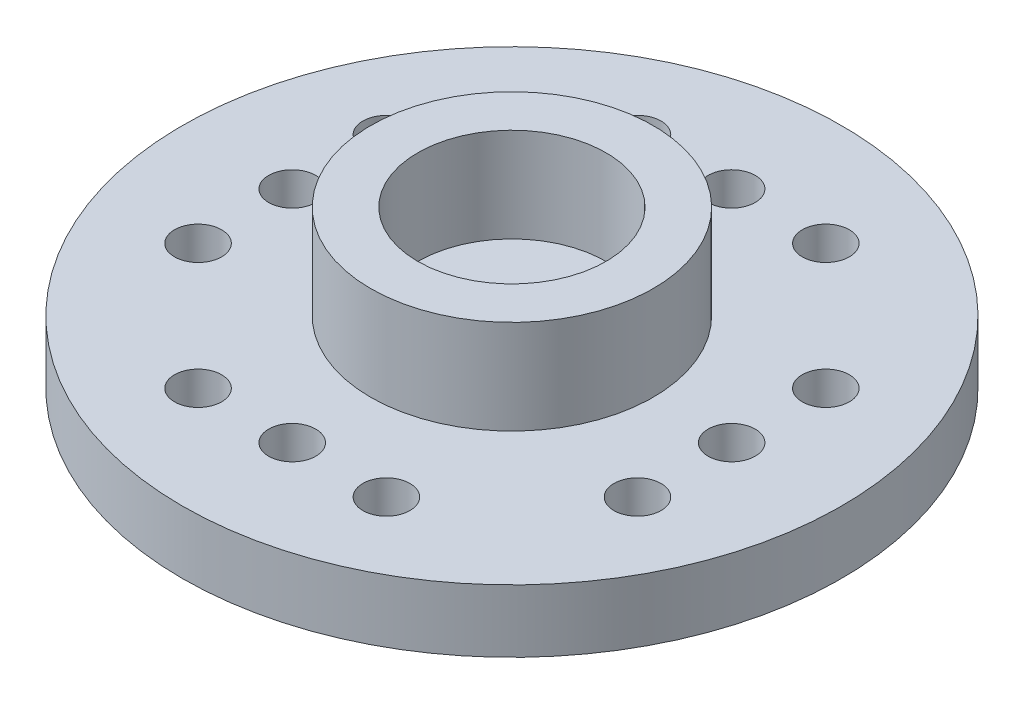
from build123d import *

# Parameters (mm, degrees)
SKETCH1_R           = 10.5
BOSS_EXTRUDE1_DEPTH = 2
SKETCH2_R           = 4.5
SKETCH2_R_2         = 3
BOSS_EXTRUDE2_DEPTH = 3
SKETCH3_R           = 1
CUT_EXTRUDE1_DEPTH  = 3
SKETCH4_R           = 4.25
SKETCH4_R_2         = 3.25
SKETCH4_R_3         = 2.75
SKETCH4_R_4         = 1
CUT_EXTRUDE2_DEPTH  = 0.5
SKETCH5_R           = 0.75
CUT_EXTRUDE3_DEPTH  = 2.5
SKETCH7_R           = 0.75
CUT_EXTRUDE4_DEPTH  = 2.5


with BuildPart() as part:
    # Sketch1 → Boss-Extrude1 (new body)
    with BuildSketch(Plane(origin=(0, 0, 0), x_dir=(1, 0, 0), z_dir=(0, 1, 0))):
        Circle(SKETCH1_R)
    extrude(amount=BOSS_EXTRUDE1_DEPTH)

    # Sketch2 → Boss-Extrude2 (add)
    with BuildSketch(Plane(origin=(0, 2, 0), x_dir=(1, 0, 0), z_dir=(0, 1, 0))):
        Circle(SKETCH2_R)
        Circle(SKETCH2_R_2, mode=Mode.SUBTRACT)
    extrude(amount=BOSS_EXTRUDE2_DEPTH)

    # Sketch3 → Cut-Extrude1 (cut)
    with BuildSketch(Plane(origin=(0, 2, 0), x_dir=(1, 0, 0), z_dir=(0, 1, 0))):
        Circle(SKETCH3_R)
    extrude(amount=-CUT_EXTRUDE1_DEPTH, mode=Mode.SUBTRACT)

    # Sketch4 → Cut-Extrude2 (cut)
    with BuildSketch(Plane.XZ):
        Circle(SKETCH4_R)
        Circle(SKETCH4_R_2, mode=Mode.SUBTRACT)
        Circle(SKETCH4_R_3)
        Circle(SKETCH4_R_4, mode=Mode.SUBTRACT)
    extrude(amount=-CUT_EXTRUDE2_DEPTH, mode=Mode.SUBTRACT)

    # Sketch5 → Cut-Extrude3 (cut)
    with BuildSketch(Plane.XZ):
        with Locations((0, 7)):
            Circle(SKETCH5_R)
        with Locations((3, 7)):
            Circle(SKETCH5_R)
        with Locations((-3, 7)):
            Circle(SKETCH5_R)
    cut_extrude3 = extrude(amount=-CUT_EXTRUDE3_DEPTH, mode=Mode.SUBTRACT)

    # Mirror1: Cut-Extrude3 across plane
    add(cut_extrude3.mirror(Plane.XY), mode=Mode.SUBTRACT)

    # Sketch7 → Cut-Extrude4 (cut)
    with BuildSketch(Plane.XZ):
        with Locations((7, 0)):
            Circle(SKETCH7_R)
        with Locations((7, 3)):
            Circle(SKETCH7_R)
        with Locations((7, -3)):
            Circle(SKETCH7_R)
    cut_extrude4 = extrude(amount=-CUT_EXTRUDE4_DEPTH, mode=Mode.SUBTRACT)

    # Mirror2: Cut-Extrude4 across plane
    add(cut_extrude4.mirror(Plane(origin=(0, 0, 0), x_dir=(0, 0, 1), z_dir=(1, 0, 0))), mode=Mode.SUBTRACT)


solid = part.part
